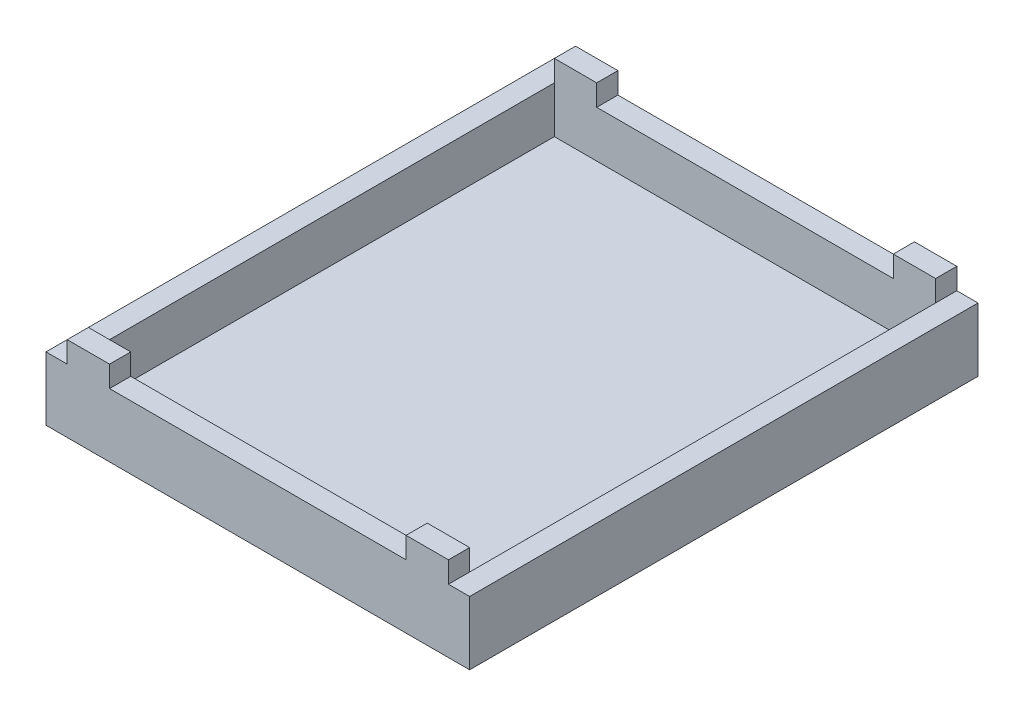
from build123d import *

# Parameters (mm, degrees)
SKETCH1_W           = 100
SKETCH1_H           = 120
BOSS_EXTRUDE1_DEPTH = 20
SKETCH2_W           = 90
SKETCH2_H           = 110
CUT_EXTRUDE1_DEPTH  = 16
SKETCH4_W           = 5
SKETCH4_H           = 5
SKETCH4_W_2         = 70
CUT_EXTRUDE2_DEPTH  = 121


with BuildPart() as part:
    # Sketch1 → Boss-Extrude1 (new body)
    with BuildSketch(Plane(origin=(0, 0, 0), x_dir=(1, 0, 0), z_dir=(0, 1, 0))):
        Rectangle(SKETCH1_W, SKETCH1_H)
    extrude(amount=BOSS_EXTRUDE1_DEPTH)

    # Sketch2 → Cut-Extrude1 (cut)
    with BuildSketch(Plane(origin=(0, 20, 0), x_dir=(1, 0, 0), z_dir=(0, 1, 0))):
        Rectangle(SKETCH2_W, SKETCH2_H)
    extrude(amount=-CUT_EXTRUDE1_DEPTH, mode=Mode.SUBTRACT)

    # Sketch4 → Cut-Extrude2 (cut, through all)
    with BuildSketch(Plane.XY.offset(60)):
        with Locations((-47.5, 17.5)):
            Rectangle(SKETCH4_W, SKETCH4_H)
        with Locations((47.5, 17.5)):
            Rectangle(SKETCH4_W, SKETCH4_H)
        with Locations((0, 17.5)):
            Rectangle(SKETCH4_W_2, SKETCH4_H)
    extrude(amount=-CUT_EXTRUDE2_DEPTH, mode=Mode.SUBTRACT)


solid = part.part
